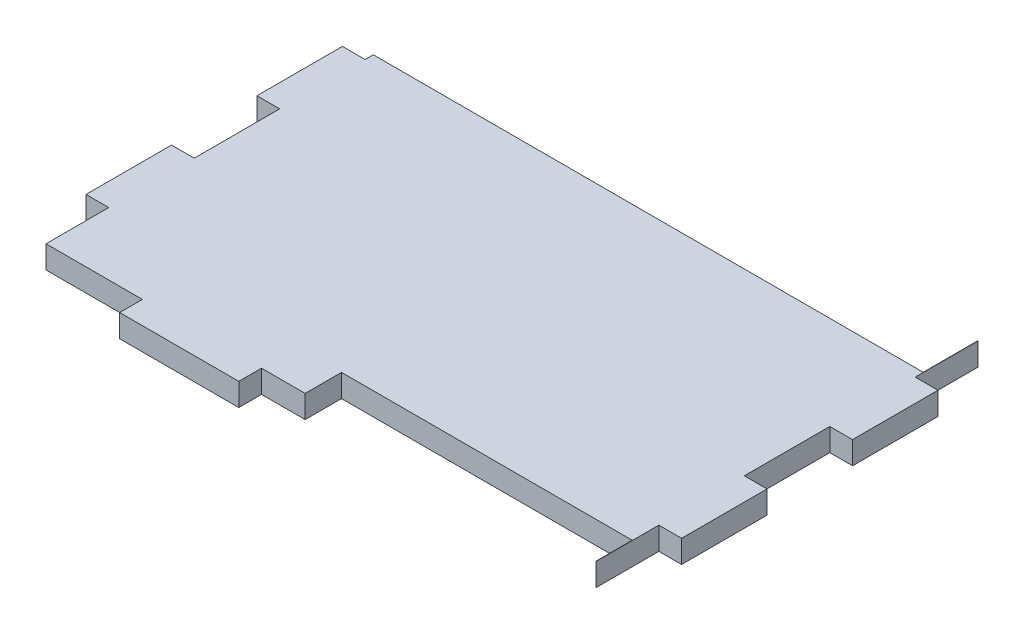
from build123d import *

# Parameters (mm, degrees)
SKETCH1_W           = 83.185
SKETCH1_H           = 59.69
BOSS_EXTRUDE1_DEPTH = 3.175
SKETCH2_W           = 16.637
SKETCH2_H           = 3.175
CUT_EXTRUDE1_DEPTH  = 3.175
LPATTERN1_COUNT     = 3
LPATTERN1_PITCH     = 33.274
SKETCH3_W           = 3.175
SKETCH3_H           = 11.938
CUT_EXTRUDE2_DEPTH  = 3.175
LPATTERN4_COUNT     = 3
LPATTERN4_PITCH     = 23.876
SKETCH5_W           = 76.801567088
SKETCH5_H           = 11.204108434
SKETCH5_W_2         = 40.606567088
SKETCH5_H_2         = 13.017856784
CUT_EXTRUDE4_DEPTH  = 3.175


with BuildPart() as part:
    # Sketch1 → Boss-Extrude1 (new body)
    with BuildSketch(Plane(origin=(0, 0, 0), x_dir=(1, 0, 0), z_dir=(0, 1, 0))):
        Rectangle(SKETCH1_W, SKETCH1_H)
    extrude(amount=BOSS_EXTRUDE1_DEPTH)

    # Sketch2 → Cut-Extrude1 (cut)
    with BuildSketch(Plane(origin=(0, 3.175, 0), x_dir=(1, 0, 0), z_dir=(0, 1, 0))):
        with Locations((-33.274, 28.2575)):
            Rectangle(SKETCH2_W, SKETCH2_H)
        with Locations((-33.274, -28.2575)):
            Rectangle(SKETCH2_W, SKETCH2_H)
    cut_extrude1 = extrude(amount=-CUT_EXTRUDE1_DEPTH, mode=Mode.SUBTRACT)

    # LPattern1: Cut-Extrude1 ×3
    with Locations(*[(i * LPATTERN1_PITCH, 0, 0) for i in range(1, LPATTERN1_COUNT)]):
        add(cut_extrude1, mode=Mode.SUBTRACT)

    # Sketch3 → Cut-Extrude2 (cut)
    with BuildSketch(Plane(origin=(0, 3.175, 0), x_dir=(1, 0, 0), z_dir=(0, 1, 0))):
        with Locations((-40.005, 23.876)):
            Rectangle(SKETCH3_W, SKETCH3_H)
        with Locations((40.005, 23.876)):
            Rectangle(SKETCH3_W, SKETCH3_H)
    cut_extrude2 = extrude(amount=-CUT_EXTRUDE2_DEPTH, mode=Mode.SUBTRACT)

    # LPattern4: Cut-Extrude2 ×3
    with Locations(*[(0, 0, i * LPATTERN4_PITCH) for i in range(1, LPATTERN4_COUNT)]):
        add(cut_extrude2, mode=Mode.SUBTRACT)

    # Sketch5 → Cut-Extrude4 (cut)
    with BuildSketch(Plane(origin=(0, 3.175, 0), x_dir=(1, 0, 0), z_dir=(0, 1, 0))):
        with Locations((-0.016716456, 24.652054217)):
            Rectangle(SKETCH5_W, SKETCH5_H)
        with Locations((18.080783544, -28.098928392)):
            Rectangle(SKETCH5_W_2, SKETCH5_H_2)
    extrude(amount=-CUT_EXTRUDE4_DEPTH, mode=Mode.SUBTRACT)


solid = part.part
